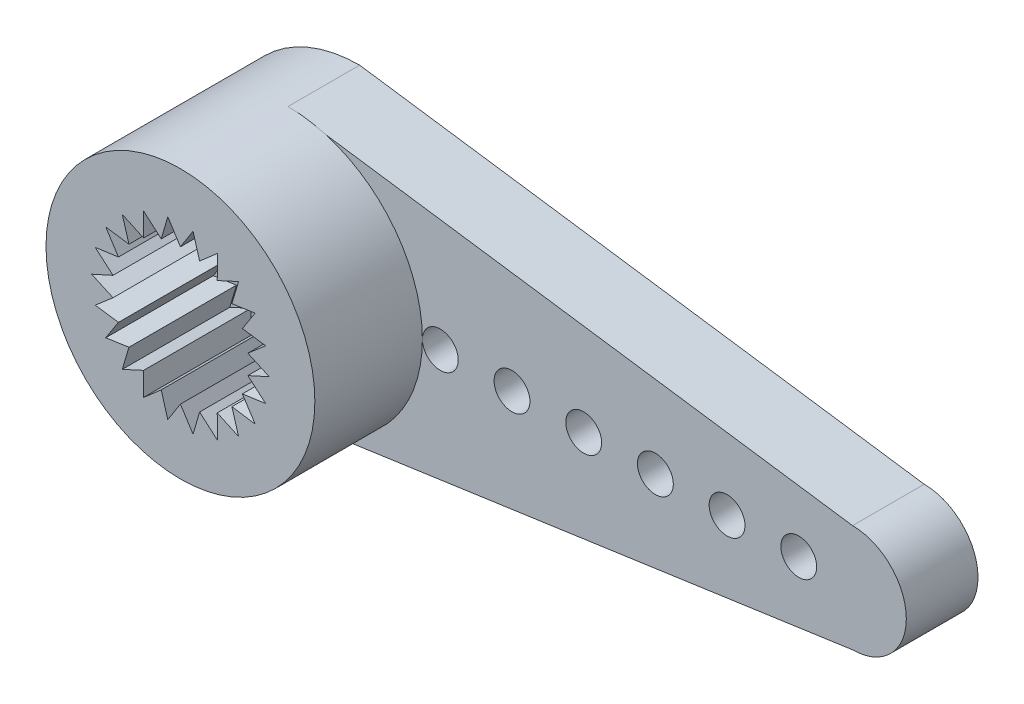
from build123d import *

# Parameters (mm, degrees)
SKETCH_1_R          = 0.5
EXTRUDE_1_DEPTH     = 2
SKETCH_2_R          = 2.5
CUT_EXTRUDE_1_DEPTH = 1.5
SKETCH_3_R          = 3.75
EXTRUDE_2_DEPTH     = 3
SKETCH_4_R          = 1.3
CUT_EXTRUDE_2_DEPTH = 9
SKETCH_5_R          = 1.3
CUT_EXTRUDE_4_DEPTH = 3


with BuildPart() as part:
    # 草图1 → 凸台-拉伸1 (new body)
    with BuildSketch(Plane.XY):
        with BuildLine():
            Line((0, 3.75), (15.75, 1.5))
            ThreePointArc((15.75, 1.5), (17.25, 0), (15.75, -1.5))
            Line((15.75, -1.5), (0, -3.75))
            ThreePointArc((0, -3.75), (-3.75, 0), (0, 3.75))
        make_face()
        with Locations((14.25, 0)):
            Circle(SKETCH_1_R, mode=Mode.SUBTRACT)
        with Locations((12.25, 0)):
            Circle(SKETCH_1_R, mode=Mode.SUBTRACT)
        with Locations((10.25, 0)):
            Circle(SKETCH_1_R, mode=Mode.SUBTRACT)
        with Locations((8.25, 0)):
            Circle(SKETCH_1_R, mode=Mode.SUBTRACT)
        with Locations((6.25, 0)):
            Circle(SKETCH_1_R, mode=Mode.SUBTRACT)
        with Locations((4.25, 0)):
            Circle(SKETCH_1_R, mode=Mode.SUBTRACT)
    extrude(amount=EXTRUDE_1_DEPTH)

    # 草图2 → 切除-拉伸1 (cut)
    with BuildSketch(Plane(origin=(0, 0, 0), x_dir=(-1, 0, 0), z_dir=(0, 0, -1))):
        Circle(SKETCH_2_R)
    extrude(amount=-CUT_EXTRUDE_1_DEPTH, mode=Mode.SUBTRACT)

    # 草图3 → 凸台-拉伸2 (add)
    with BuildSketch(Plane.XY.offset(2)):
        Circle(SKETCH_3_R)
    extrude(amount=EXTRUDE_2_DEPTH)

    # 草图4 → 切除-拉伸2 (cut)
    with BuildSketch(Plane(origin=(0, 0, 1.5), x_dir=(-1, 0, 0), z_dir=(0, 0, -1))):
        Circle(SKETCH_4_R)
    extrude(amount=-CUT_EXTRUDE_2_DEPTH, mode=Mode.SUBTRACT)

    # 草图5 → 切除-拉伸4 (cut)
    with BuildSketch(Plane.XY.offset(5)):
        Polygon((0, -1.939028966), (0.352599159, -2.491409984), (0.535291858, -1.862065615), (1.02923199, -2.292732659), (1.027217553, -1.637410678), (1.622482567, -1.911473664), (1.435924191, -1.28326436), (2.084289255, -1.378520335), (1.728300791, -0.82831749), (2.377239224, -0.737049382), (1.88066074, -0.309427158), (2.477599408, -0.039028966), (1.88066074, 0.231369227), (2.377239224, 0.658991451), (1.728300791, 0.750259559), (2.084289255, 1.300462404), (1.435924191, 1.205206429), (1.622482567, 1.833415733), (1.027217553, 1.559352747), (1.02923199, 2.214674728), (0.535291858, 1.784007684), (0.352599159, 2.413352053), (0, 1.860971034), (-0.352599159, 2.413352053), (-0.535291858, 1.784007684), (-1.02923199, 2.214674728), (-1.027217553, 1.559352747), (-1.622482567, 1.833415733), (-1.435924191, 1.205206429), (-2.084289255, 1.300462404), (-1.728300791, 0.750259559), (-2.377239224, 0.658991451), (-1.88066074, 0.231369227), (-2.477599408, -0.039028966), (-1.88066074, -0.309427158), (-2.377239224, -0.737049382), (-1.728300791, -0.82831749), (-2.084289255, -1.378520335), (-1.435924191, -1.28326436), (-1.622482567, -1.911473664), (-1.027217553, -1.637410678), (-1.02923199, -2.292732659), (-0.535291858, -1.862065615), (-0.352599159, -2.491409984), align=None)
        Circle(SKETCH_5_R, mode=Mode.SUBTRACT)
    extrude(amount=-CUT_EXTRUDE_4_DEPTH, mode=Mode.SUBTRACT)


solid = part.part
